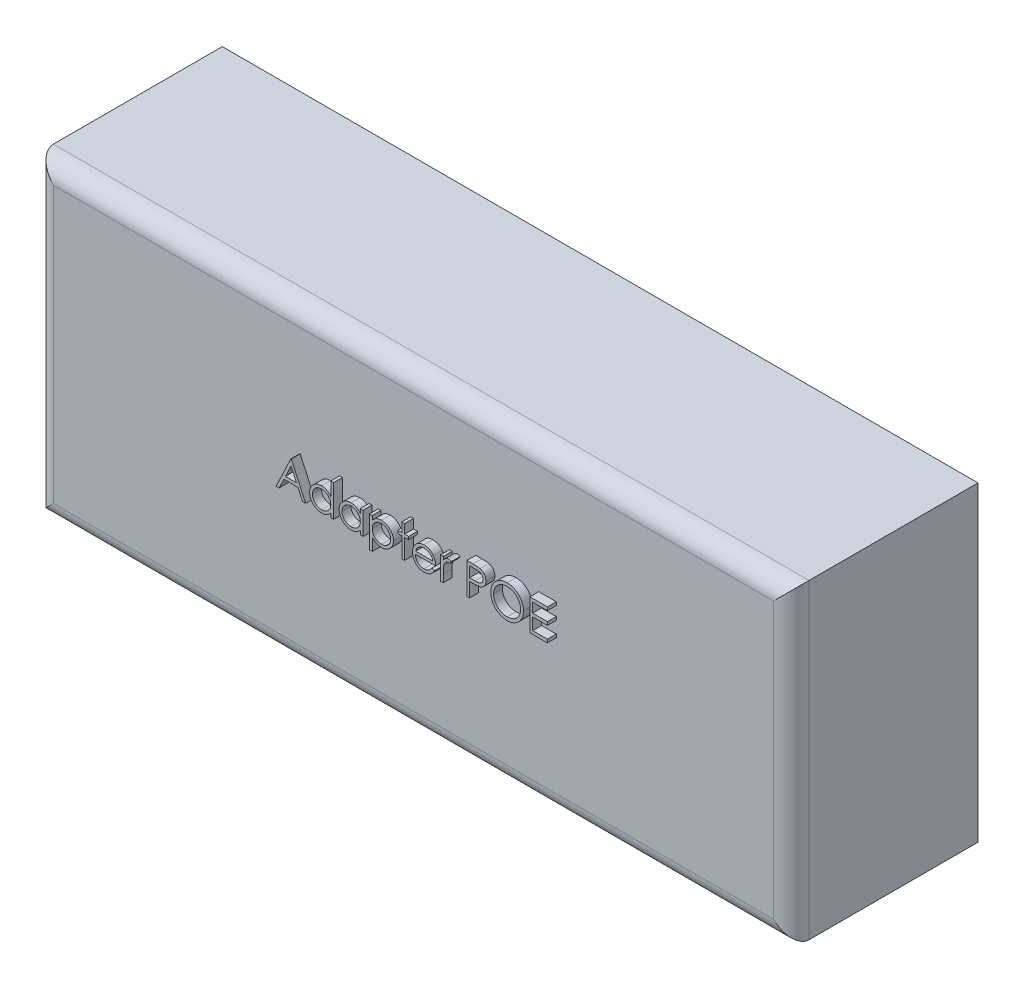
from build123d import *

# Parameters (mm, degrees)
SKETCH1_W           = 85
SKETCH1_H           = 35
BOSS_EXTRUDE1_DEPTH = 21
FILLET1_R           = 2
BOSS_EXTRUDE2_DEPTH = 1


with BuildPart() as part:
    # Sketch1 → Boss-Extrude1 (new body)
    with BuildSketch(Plane.XY):
        Rectangle(SKETCH1_W, SKETCH1_H)
    extrude(amount=BOSS_EXTRUDE1_DEPTH)

    # Fillet1
    fillet1_edges = [part.edges().sort_by_distance(p)[0] for p in [
        (-42.5, 0, 21),
        (0, -17.5, 21),
        (42.5, 0, 21),
        (0, 17.5, 21),
    ]]
    fillet(fillet1_edges, radius=FILLET1_R)

    # Sketch2 → Boss-Extrude2 (add)
    with BuildSketch(Plane.XY.offset(21)):
        Polygon((-12.739406082, 3.203500966), (-11.124021466, -0.296499034), (-11.46546778, -0.296499034), (-11.982895665, 0.825295838), (-13.569534287, 0.825295838), (-14.101685729, -0.296499034), (-14.444534287, -0.296499034), (-12.784277877, 3.203500966), align=None)
        Polygon((-12.765347588, 2.521309459), (-13.399161691, 1.184270197), (-12.148360409, 1.184270197), align=None, mode=Mode.SUBTRACT)
        with BuildLine():
            Line((-7.982995825, 3.293244556), (-7.982995825, -0.296499034))
            Line((-7.982995825, -0.296499034), (-8.297098389, -0.296499034))
            Line((-8.297098389, -0.296499034), (-8.297098389, 0.145908818))
            add(Edge.make_bspline(
                [(-8.297098389, 0.145908818), (-8.33251718, 0.105869225), (-8.401637395, 0.027731453), (-8.517078513, -0.074350719), (-8.639446691, -0.158729041), (-8.768148012, -0.226878956), (-8.903066256, -0.278071013), (-9.043902343, -0.314457172), (-9.190713724, -0.337851007), (-9.290966079, -0.340187029), (-9.341769864, -0.341370829)],
                knots=[0, 0, 0, 0, 0.000160263, 0.000312755, 0.000460949, 0.000605216, 0.000748578, 0.000892786, 0.001041028, 0.001193333, 0.001193333, 0.001193333, 0.001193333], degree=3))
            add(Edge.make_bspline(
                [(-9.341769864, -0.341370829), (-9.386937818, -0.340144457), (-9.476011022, -0.337725996), (-9.6070401, -0.318963693), (-9.733132349, -0.288833071), (-9.854406922, -0.246932182), (-9.970079067, -0.19135136), (-10.081139164, -0.124810112), (-10.187011856, -0.045569282), (-10.286083395, 0.045018747), (-10.377315395, 0.143413734), (-10.457376668, 0.248359281), (-10.524129748, 0.359401585), (-10.579949828, 0.475134738), (-10.622946173, 0.596449658), (-10.652919807, 0.722926826), (-10.671660254, 0.854416699), (-10.674077714, 0.943956223), (-10.675303518, 0.989358338)],
                knots=[0, 0, 0, 0, 0.000135464, 0.00026714, 0.000396211, 0.000523931, 0.000651257, 0.000780517, 0.000911767, 0.001047265, 0.00118272, 0.001313831, 0.001442491, 0.001570752, 0.001698704, 0.001827775, 0.001960146, 0.00209631, 0.00209631, 0.00209631, 0.00209631], degree=3))
            add(Edge.make_bspline(
                [(-10.675303518, 0.989358338), (-10.674050546, 1.033822041), (-10.671573489, 1.121724385), (-10.653120269, 1.251003083), (-10.622089261, 1.375521343), (-10.578541413, 1.494878287), (-10.522699458, 1.609218337), (-10.454771371, 1.718622362), (-10.374752246, 1.823391759), (-10.282499839, 1.921062986), (-10.182565069, 2.0112836), (-10.075656338, 2.089692646), (-9.964433057, 2.157409495), (-9.847170047, 2.211062971), (-9.725602942, 2.254472075), (-9.598649496, 2.284505043), (-9.466837917, 2.302202365), (-9.377347425, 2.304765129), (-9.331954159, 2.306065068)],
                knots=[0, 0, 0, 0, 0.000133363, 0.00026365, 0.000390846, 0.000517716, 0.000644083, 0.000771912, 0.000903449, 0.001038867, 0.001174416, 0.001306792, 0.001436052, 0.00156435, 0.001692963, 0.001822716, 0.001954992, 0.002091156, 0.002091156, 0.002091156, 0.002091156], degree=3))
            add(Edge.make_bspline(
                [(-9.331954159, 2.306065068), (-9.279737351, 2.304497972), (-9.17724156, 2.301421937), (-9.027343039, 2.27571557), (-8.885555428, 2.232552692), (-8.751062441, 2.173461411), (-8.62466588, 2.09666066), (-8.50543924, 2.003909212), (-8.395455917, 1.892582066), (-8.330384094, 1.808970492), (-8.297098389, 1.766201286)],
                knots=[0, 0, 0, 0, 0.000156576, 0.000307342, 0.000454614, 0.000600266, 0.00074684, 0.00089719, 0.001052366, 0.001214863, 0.001214863, 0.001214863, 0.001214863], degree=3))
            Line((-8.297098389, 1.766201286), (-8.297098389, 3.293244556))
            Line((-8.297098389, 3.293244556), (-7.982995825, 3.293244556))
        make_face()
        with BuildLine():
            add(Edge.make_bspline(
                [(-9.327747428, 1.991962504), (-9.373661766, 1.990328867), (-9.464289366, 1.987104326), (-9.597333368, 1.96193083), (-9.724646782, 1.920046236), (-9.845592856, 1.862764335), (-9.958261073, 1.790735598), (-10.058954744, 1.703614215), (-10.148497445, 1.603777201), (-10.223805709, 1.49167509), (-10.285196206, 1.371496999), (-10.328363238, 1.245872561), (-10.356832485, 1.117067584), (-10.359741006, 1.029704898), (-10.361200953, 0.985852729)],
                knots=[0, 0, 0, 0, 0.000137677, 0.000271753, 0.000404561, 0.000538791, 0.000672205, 0.000804452, 0.00093703, 0.001073348, 0.00120849, 0.001340643, 0.001470999, 0.001602378, 0.001602378, 0.001602378, 0.001602378], degree=3))
            add(Edge.make_bspline(
                [(-10.361200953, 0.985852729), (-10.35933606, 0.942262622), (-10.355613583, 0.855253266), (-10.328862889, 0.726272689), (-10.283983015, 0.600618647), (-10.222740953, 0.479357653), (-10.146054328, 0.366773553), (-10.057165675, 0.26503343), (-9.955215394, 0.177543842), (-9.842287887, 0.104306269), (-9.721679917, 0.045143748), (-9.594845985, 0.003978108), (-9.464170347, -0.022599672), (-9.375318013, -0.025704149), (-9.330551915, -0.027268265)],
                knots=[0, 0, 0, 0, 0.000130727, 0.000260941, 0.000393327, 0.000530037, 0.000667328, 0.000800955, 0.000934191, 0.001068956, 0.001203792, 0.001335934, 0.001468075, 0.001602253, 0.001602253, 0.001602253, 0.001602253], degree=3))
            add(Edge.make_bspline(
                [(-9.330551915, -0.027268265), (-9.285105412, -0.025608301), (-9.194716826, -0.022306797), (-9.061278118, 0.002974468), (-8.931783155, 0.044743266), (-8.807995927, 0.102642393), (-8.692679795, 0.174399749), (-8.589181918, 0.25840684), (-8.501665949, 0.356110024), (-8.42747334, 0.463486477), (-8.369297923, 0.581198474), (-8.326921864, 0.706532664), (-8.301867958, 0.839493412), (-8.298710229, 0.930357339), (-8.297098389, 0.976738145)],
                knots=[0, 0, 0, 0, 0.000136278, 0.000271043, 0.000405851, 0.000543552, 0.000679927, 0.000812429, 0.000941985, 0.001072088, 0.00120284, 0.001334538, 0.001467925, 0.001607002, 0.001607002, 0.001607002, 0.001607002], degree=3))
            add(Edge.make_bspline(
                [(-8.297098389, 0.976738145), (-8.298058046, 1.012075976), (-8.299946953, 1.081632009), (-8.314377523, 1.183759527), (-8.337332449, 1.281493253), (-8.369678619, 1.374935942), (-8.412169904, 1.463570957), (-8.463417669, 1.548034718), (-8.524323119, 1.627887929), (-8.593905815, 1.702031), (-8.670071018, 1.769657462), (-8.750665558, 1.830021703), (-8.836644305, 1.879610476), (-8.926561342, 1.920651747), (-9.020572677, 1.953310897), (-9.119443297, 1.975098591), (-9.222122283, 1.990058912), (-9.292168339, 1.991321293), (-9.327747428, 1.991962504)],
                knots=[0, 0, 0, 0, 0.000105983, 0.000208608, 0.000308773, 0.00040678, 0.000504626, 0.000603105, 0.000702667, 0.00080535, 0.000907651, 0.001007914, 0.001106881, 0.00120477, 0.001304102, 0.001404791, 0.00150811, 0.001614764, 0.001614764, 0.001614764, 0.001614764], degree=3))
        make_face(mode=Mode.SUBTRACT)
        with BuildLine():
            Line((-4.662483005, 2.261193274), (-4.662483005, -0.296499034))
            Line((-4.662483005, -0.296499034), (-4.976585569, -0.296499034))
            Line((-4.976585569, -0.296499034), (-4.976585569, 0.145908818))
            add(Edge.make_bspline(
                [(-4.976585569, 0.145908818), (-5.012004359, 0.105869225), (-5.081124575, 0.027731453), (-5.196565693, -0.074350719), (-5.318933871, -0.158729041), (-5.447635192, -0.226878956), (-5.582553435, -0.278071013), (-5.723389522, -0.314457172), (-5.870200903, -0.337851007), (-5.970453258, -0.340187029), (-6.021257043, -0.341370829)],
                knots=[0, 0, 0, 0, 0.000160263, 0.000312755, 0.000460949, 0.000605216, 0.000748578, 0.000892786, 0.001041028, 0.001193333, 0.001193333, 0.001193333, 0.001193333], degree=3))
            add(Edge.make_bspline(
                [(-6.021257043, -0.341370829), (-6.066424997, -0.340144457), (-6.155498202, -0.337725996), (-6.286527279, -0.318963693), (-6.412619528, -0.288833071), (-6.533894101, -0.246932182), (-6.649566247, -0.19135136), (-6.760626343, -0.124810112), (-6.866499035, -0.045569282), (-6.965570574, 0.045018747), (-7.056802575, 0.143413734), (-7.136863847, 0.248359281), (-7.203616927, 0.359401585), (-7.259437008, 0.475134738), (-7.302433352, 0.596449658), (-7.332406986, 0.722926826), (-7.351147433, 0.854416699), (-7.353564894, 0.943956223), (-7.354790697, 0.989358338)],
                knots=[0, 0, 0, 0, 0.000135464, 0.00026714, 0.000396211, 0.000523931, 0.000651257, 0.000780517, 0.000911767, 0.001047265, 0.00118272, 0.001313831, 0.001442491, 0.001570752, 0.001698704, 0.001827775, 0.001960146, 0.00209631, 0.00209631, 0.00209631, 0.00209631], degree=3))
            add(Edge.make_bspline(
                [(-7.354790697, 0.989358338), (-7.353537726, 1.033822041), (-7.351060669, 1.121724385), (-7.332607449, 1.251003083), (-7.30157644, 1.375521343), (-7.258028593, 1.494878287), (-7.202186638, 1.609218337), (-7.134258551, 1.718622362), (-7.054239426, 1.823391759), (-6.961987019, 1.921062986), (-6.862052249, 2.0112836), (-6.755143518, 2.089692646), (-6.643920237, 2.157409495), (-6.526657226, 2.211062971), (-6.405090121, 2.254472075), (-6.278136675, 2.284505043), (-6.146325097, 2.302202365), (-6.056834605, 2.304765129), (-6.011441338, 2.306065068)],
                knots=[0, 0, 0, 0, 0.000133363, 0.00026365, 0.000390846, 0.000517716, 0.000644083, 0.000771912, 0.000903449, 0.001038867, 0.001174416, 0.001306792, 0.001436052, 0.00156435, 0.001692963, 0.001822716, 0.001954992, 0.002091156, 0.002091156, 0.002091156, 0.002091156], degree=3))
            add(Edge.make_bspline(
                [(-6.011441338, 2.306065068), (-5.959241479, 2.304627317), (-5.856880019, 2.301807954), (-5.70715201, 2.278345227), (-5.565507532, 2.23870676), (-5.43085318, 2.184789262), (-5.303672494, 2.113140532), (-5.185169509, 2.022760571), (-5.074104026, 1.914219384), (-5.009723734, 1.83084894), (-4.976585569, 1.787936062)],
                knots=[0, 0, 0, 0, 0.00015654, 0.000306968, 0.000453261, 0.000596998, 0.000741098, 0.000889738, 0.001042937, 0.001205434, 0.001205434, 0.001205434, 0.001205434], degree=3))
            Line((-4.976585569, 1.787936062), (-4.976585569, 2.261193274))
            Line((-4.976585569, 2.261193274), (-4.662483005, 2.261193274))
        make_face()
        with BuildLine():
            add(Edge.make_bspline(
                [(-6.007234607, 1.991962504), (-6.053148945, 1.990328867), (-6.143776545, 1.987104326), (-6.276820547, 1.96193083), (-6.404133961, 1.920046236), (-6.525080036, 1.862764335), (-6.637748252, 1.790735598), (-6.738441923, 1.703614215), (-6.827984624, 1.603777201), (-6.903292889, 1.49167509), (-6.964683386, 1.371496999), (-7.007850417, 1.245872561), (-7.036319665, 1.117067584), (-7.039228185, 1.029704898), (-7.040688133, 0.985852729)],
                knots=[0, 0, 0, 0, 0.000137677, 0.000271753, 0.000404561, 0.000538791, 0.000672205, 0.000804452, 0.00093703, 0.001073348, 0.00120849, 0.001340643, 0.001470999, 0.001602378, 0.001602378, 0.001602378, 0.001602378], degree=3))
            add(Edge.make_bspline(
                [(-7.040688133, 0.985852729), (-7.03882324, 0.942262622), (-7.035100763, 0.855253266), (-7.008350068, 0.726272689), (-6.963470195, 0.600618647), (-6.902228132, 0.479357653), (-6.825541507, 0.366773553), (-6.736652855, 0.26503343), (-6.634702574, 0.177543842), (-6.521775067, 0.104306269), (-6.401167096, 0.045143748), (-6.274333165, 0.003978108), (-6.143657526, -0.022599672), (-6.054805193, -0.025704149), (-6.010039094, -0.027268265)],
                knots=[0, 0, 0, 0, 0.000130727, 0.000260941, 0.000393327, 0.000530037, 0.000667328, 0.000800955, 0.000934191, 0.001068956, 0.001203792, 0.001335934, 0.001468075, 0.001602253, 0.001602253, 0.001602253, 0.001602253], degree=3))
            add(Edge.make_bspline(
                [(-6.010039094, -0.027268265), (-5.964592592, -0.025608301), (-5.874204005, -0.022306797), (-5.740765297, 0.002974468), (-5.611270334, 0.044743266), (-5.487483106, 0.102642393), (-5.372166975, 0.174399749), (-5.268669097, 0.25840684), (-5.181153129, 0.356110024), (-5.106960519, 0.463486477), (-5.048785103, 0.581198474), (-5.006409044, 0.706532664), (-4.981355138, 0.839493412), (-4.978197408, 0.930357339), (-4.976585569, 0.976738145)],
                knots=[0, 0, 0, 0, 0.000136278, 0.000271043, 0.000405851, 0.000543552, 0.000679927, 0.000812429, 0.000941985, 0.001072088, 0.00120284, 0.001334538, 0.001467925, 0.001607002, 0.001607002, 0.001607002, 0.001607002], degree=3))
            add(Edge.make_bspline(
                [(-4.976585569, 0.976738145), (-4.977545225, 1.012075976), (-4.979434133, 1.081632009), (-4.993864702, 1.183759527), (-5.016819629, 1.281493253), (-5.049165799, 1.374935942), (-5.091657083, 1.463570957), (-5.142904849, 1.548034718), (-5.203810299, 1.627887929), (-5.273392995, 1.702031), (-5.349558197, 1.769657462), (-5.430152738, 1.830021703), (-5.516131485, 1.879610476), (-5.606048522, 1.920651747), (-5.700059856, 1.953310897), (-5.798930476, 1.975098591), (-5.901609463, 1.990058912), (-5.971655518, 1.991321293), (-6.007234607, 1.991962504)],
                knots=[0, 0, 0, 0, 0.000105983, 0.000208608, 0.000308773, 0.00040678, 0.000504626, 0.000603105, 0.000702667, 0.00080535, 0.000907651, 0.001007914, 0.001106881, 0.00120477, 0.001304102, 0.001404791, 0.00150811, 0.001614764, 0.001614764, 0.001614764, 0.001614764], degree=3))
        make_face(mode=Mode.SUBTRACT)
        with BuildLine():
            Line((-3.944534287, 2.261193274), (-3.630431723, 2.261193274))
            Line((-3.630431723, 2.261193274), (-3.630431723, 1.787936062))
            add(Edge.make_bspline(
                [(-3.630431723, 1.787936062), (-3.597074239, 1.830873796), (-3.532250644, 1.914314689), (-3.420525739, 2.022304817), (-3.30259893, 2.113380121), (-3.175435518, 2.184762654), (-3.041011828, 2.238583466), (-2.89987951, 2.278362916), (-2.750840745, 2.30180439), (-2.648944293, 2.304626052), (-2.596978197, 2.306065068)],
                knots=[0, 0, 0, 0, 0.00016294, 0.00031664, 0.000464722, 0.000608822, 0.000752559, 0.000898176, 0.001047911, 0.001203751, 0.001203751, 0.001203751, 0.001203751], degree=3))
            add(Edge.make_bspline(
                [(-2.596978197, 2.306065068), (-2.551586594, 2.30475189), (-2.461867706, 2.302156323), (-2.329804477, 2.284583268), (-2.202629093, 2.254465576), (-2.081061039, 2.21106466), (-1.963797974, 2.15740919), (-1.852575874, 2.089692155), (-1.745662318, 2.011285964), (-1.645746129, 1.921053813), (-1.553424762, 1.823425547), (-1.473578581, 1.718403242), (-1.404706676, 1.609440656), (-1.34903638, 1.494848564), (-1.305428033, 1.375529334), (-1.274413355, 1.251000893), (-1.255955711, 1.121724953), (-1.25347926, 1.033822232), (-1.252226594, 0.989358338)],
                knots=[0, 0, 0, 0, 0.000136164, 0.000269135, 0.000398888, 0.000527501, 0.000655799, 0.000785059, 0.000917435, 0.001052984, 0.001188402, 0.001319939, 0.001448139, 0.001574506, 0.001701376, 0.001828571, 0.001958859, 0.002092222, 0.002092222, 0.002092222, 0.002092222], degree=3))
            add(Edge.make_bspline(
                [(-1.252226594, 0.989358338), (-1.25345208, 0.943956029), (-1.255868914, 0.854416125), (-1.27461392, 0.722929027), (-1.304570794, 0.596441654), (-1.347628978, 0.47516439), (-1.403270466, 0.359180739), (-1.470975026, 0.248574343), (-1.550861493, 0.14338064), (-1.642162621, 0.045027739), (-1.741215557, -0.045571573), (-1.847093047, -0.124809643), (-1.958151972, -0.191351018), (-2.073824139, -0.246933978), (-2.195099778, -0.288826162), (-2.321413056, -0.319043963), (-2.452695202, -0.337678458), (-2.541996354, -0.340130601), (-2.587162492, -0.341370829)],
                knots=[0, 0, 0, 0, 0.000136164, 0.000268535, 0.000397606, 0.000525558, 0.00065382, 0.000782843, 0.000913955, 0.001049409, 0.001184907, 0.001316158, 0.001445417, 0.001572744, 0.001700463, 0.001829535, 0.001961906, 0.002097369, 0.002097369, 0.002097369, 0.002097369], degree=3))
            add(Edge.make_bspline(
                [(-2.587162492, -0.341370829), (-2.637990064, -0.340076021), (-2.73838942, -0.337518396), (-2.88518709, -0.311598986), (-3.026463942, -0.272862051), (-3.160654767, -0.216163057), (-3.288822579, -0.143907541), (-3.410242385, -0.055797335), (-3.525559138, 0.04798329), (-3.594967895, 0.126715106), (-3.630431723, 0.166942472)],
                knots=[0, 0, 0, 0, 0.000152339, 0.000300914, 0.000445856, 0.000591043, 0.000736709, 0.000886352, 0.001040245, 0.001201023, 0.001201023, 0.001201023, 0.001201023], degree=3))
            Line((-3.630431723, 0.166942472), (-3.630431723, -1.238806726))
            Line((-3.630431723, -1.238806726), (-3.944534287, -1.238806726))
            Line((-3.944534287, -1.238806726), (-3.944534287, 2.261193274))
        make_face()
        with BuildLine():
            add(Edge.make_bspline(
                [(-2.599782684, 1.991962504), (-2.635362247, 1.991322246), (-2.705409234, 1.990061743), (-2.808081453, 1.975087794), (-2.906976881, 1.953350053), (-3.001098833, 1.920438153), (-3.091349449, 1.880039339), (-3.177033614, 1.829557328), (-3.258091181, 1.769905322), (-3.334318212, 1.702225978), (-3.403181505, 1.62765129), (-3.464144433, 1.548063481), (-3.515351738, 1.463563342), (-3.557853759, 1.374937979), (-3.590197041, 1.281492694), (-3.613152761, 1.183759681), (-3.627583114, 1.081631969), (-3.629472051, 1.012075962), (-3.630431723, 0.976738145)],
                knots=[0, 0, 0, 0, 0.000106654, 0.000209973, 0.000310662, 0.000409994, 0.000508521, 0.000606883, 0.00070771, 0.000810012, 0.000912217, 0.001011779, 0.001110258, 0.001208104, 0.001306111, 0.001406276, 0.001508901, 0.001614884, 0.001614884, 0.001614884, 0.001614884], degree=3))
            add(Edge.make_bspline(
                [(-3.630431723, 0.976738145), (-3.628840867, 0.930350033), (-3.625724245, 0.839471792), (-3.600386877, 0.70668767), (-3.559151613, 0.581036014), (-3.500622899, 0.463574977), (-3.426675325, 0.355592142), (-3.337577168, 0.258901536), (-3.234134617, 0.174110945), (-3.118067426, 0.102689691), (-2.993645295, 0.044701625), (-2.863859383, 0.003187414), (-2.730494502, -0.022384814), (-2.640326182, -0.025631633), (-2.594874832, -0.027268265)],
                knots=[0, 0, 0, 0, 0.000139077, 0.000272463, 0.00040394, 0.000534691, 0.000664794, 0.000795295, 0.000927798, 0.001064768, 0.001203104, 0.001338581, 0.001472656, 0.001608934, 0.001608934, 0.001608934, 0.001608934], degree=3))
            add(Edge.make_bspline(
                [(-2.594874832, -0.027268265), (-2.550339064, -0.025711888), (-2.461943571, -0.02262276), (-2.331785449, 0.004115428), (-2.205294811, 0.044960452), (-2.085114638, 0.104520009), (-1.972291151, 0.177510067), (-1.870409597, 0.2650701), (-1.781402683, 0.366560043), (-1.705538328, 0.479568546), (-1.644406843, 0.60074393), (-1.598476603, 0.726125318), (-1.57196803, 0.855270742), (-1.568211241, 0.942268454), (-1.566329159, 0.985852729)],
                knots=[0, 0, 0, 0, 0.000133479, 0.000264931, 0.000397073, 0.000531279, 0.000666044, 0.000799279, 0.000932907, 0.001069805, 0.001206515, 0.001339137, 0.001469351, 0.001600078, 0.001600078, 0.001600078, 0.001600078], degree=3))
            add(Edge.make_bspline(
                [(-1.566329159, 0.985852729), (-1.567783892, 1.029707718), (-1.570682026, 1.117076022), (-1.599229064, 1.245838925), (-1.642129042, 1.371726901), (-1.704688094, 1.49124745), (-1.778889363, 1.604021533), (-1.86863636, 1.703575412), (-1.969252556, 1.790746085), (-2.08194172, 1.862761495), (-2.202882146, 1.92004699), (-2.330197062, 1.961930628), (-2.463240664, 1.987104378), (-2.553868319, 1.990328884), (-2.599782684, 1.991962504)],
                knots=[0, 0, 0, 0, 0.000131379, 0.000261735, 0.000393889, 0.000529349, 0.000665274, 0.000797853, 0.0009301, 0.001063514, 0.001197743, 0.001330552, 0.001464627, 0.001602305, 0.001602305, 0.001602305, 0.001602305], degree=3))
        make_face(mode=Mode.SUBTRACT)
        Polygon((-0.309918902, 3.293244556), (0.004183662, 3.293244556), (0.004183662, 2.261193274), (0.452901611, 2.261193274), (0.452901611, 1.947090709), (0.004183662, 1.947090709), (0.004183662, -0.296499034), (-0.309918902, -0.296499034), (-0.309918902, 1.947090709), (-0.758636851, 1.947090709), (-0.758636851, 2.261193274), (-0.309918902, 2.261193274), align=None)
        with BuildLine():
            Line((3.090521803, 0.511193274), (3.369568277, 0.364658818))
            add(Edge.make_bspline(
                [(3.369568277, 0.364658818), (3.347331682, 0.325215487), (3.304068074, 0.248474384), (3.229667326, 0.143042524), (3.151675253, 0.048194808), (3.066571285, -0.033534846), (2.976901606, -0.104786231), (2.882168951, -0.167124056), (2.781880134, -0.220242576), (2.676030409, -0.264995104), (2.563730858, -0.299404598), (2.444709341, -0.323708819), (2.318737846, -0.338732088), (2.232391666, -0.340477229), (2.188178053, -0.341370829)],
                knots=[0, 0, 0, 0, 0.000135759, 0.000264133, 0.000386579, 0.000503597, 0.000617365, 0.000729763, 0.000843304, 0.000957371, 0.001074023, 0.001195027, 0.001321389, 0.001453992, 0.001453992, 0.001453992, 0.001453992], degree=3))
            add(Edge.make_bspline(
                [(2.188178053, -0.341370829), (2.139036075, -0.340223654), (2.043174314, -0.337985847), (1.903634567, -0.318693382), (1.772255148, -0.287221024), (1.649043445, -0.243255482), (1.534301192, -0.185828158), (1.427800338, -0.115868676), (1.328980812, -0.033736422), (1.240956602, 0.061280022), (1.16171272, 0.162961979), (1.0917869, 0.268917864), (1.033329469, 0.378881088), (0.985776859, 0.492151612), (0.947371994, 0.608015506), (0.92060529, 0.727526973), (0.905175542, 0.850362557), (0.902811096, 0.933459893), (0.901619559, 0.975335902)],
                knots=[0, 0, 0, 0, 0.000147371, 0.000287478, 0.000421649, 0.000552053, 0.000679042, 0.000805636, 0.000933558, 0.00106351, 0.001193382, 0.001319977, 0.001443869, 0.001566405, 0.001688128, 0.001809576, 0.001933238, 0.002058864, 0.002058864, 0.002058864, 0.002058864], degree=3))
            add(Edge.make_bspline(
                [(0.901619559, 0.975335902), (0.902678701, 1.014630732), (0.904777779, 1.092507897), (0.918008566, 1.207773441), (0.941456859, 1.319801894), (0.973633183, 1.428686342), (1.01518443, 1.534244476), (1.066016649, 1.63654054), (1.126209027, 1.735465679), (1.1726817, 1.797868813), (1.196090713, 1.829302248)],
                knots=[0, 0, 0, 0, 0.000117891, 0.000233644, 0.000347498, 0.000460856, 0.000573868, 0.000687374, 0.000803169, 0.000920699, 0.000920699, 0.000920699, 0.000920699], degree=3))
            add(Edge.make_bspline(
                [(1.196090713, 1.829302248), (1.227798396, 1.867171118), (1.290209343, 1.941709268), (1.395765698, 2.039647594), (1.510065894, 2.121691369), (1.63167752, 2.189698506), (1.762013994, 2.241372153), (1.899323286, 2.279879735), (2.045168872, 2.301457746), (2.144874093, 2.304505579), (2.195890393, 2.306065068)],
                knots=[0, 0, 0, 0, 0.000148071, 0.000291452, 0.00043058, 0.000569298, 0.000708346, 0.00085021, 0.000996268, 0.001149307, 0.001149307, 0.001149307, 0.001149307], degree=3))
            add(Edge.make_bspline(
                [(2.195890393, 2.306065068), (2.248337998, 2.30471102), (2.351228244, 2.302054684), (2.501260365, 2.277428351), (2.643221082, 2.238375796), (2.777053586, 2.183222006), (2.902771447, 2.112062454), (3.019557496, 2.023920613), (3.129409009, 1.921502525), (3.193317588, 1.842739316), (3.225838309, 1.80265962)],
                knots=[0, 0, 0, 0, 0.000157241, 0.00030847, 0.000454763, 0.000598116, 0.000741606, 0.000886879, 0.001036172, 0.001190853, 0.001190853, 0.001190853, 0.001190853], degree=3))
            add(Edge.make_bspline(
                [(3.225838309, 1.80265962), (3.247965248, 1.772456038), (3.292071841, 1.71224992), (3.347318941, 1.614078763), (3.395276336, 1.511368168), (3.433609297, 1.402457871), (3.464648798, 1.288638291), (3.487105617, 1.169095746), (3.500275235, 1.043865835), (3.502863933, 0.958539279), (3.504183662, 0.915039427)],
                knots=[0, 0, 0, 0, 0.000112234, 0.000223721, 0.000337279, 0.000451932, 0.000569628, 0.000690912, 0.000816421, 0.00094695, 0.00094695, 0.00094695, 0.00094695], degree=3))
            Line((3.504183662, 0.915039427), (1.215722123, 0.915039427))
            add(Edge.make_bspline(
                [(1.215722123, 0.915039427), (1.21726173, 0.881338963), (1.220289304, 0.815068359), (1.234404447, 0.718097576), (1.256653221, 0.625724234), (1.287922283, 0.538641192), (1.325789129, 0.455711065), (1.372174845, 0.377549028), (1.427514399, 0.304511098), (1.489240099, 0.23594396), (1.557947194, 0.174883199), (1.630229941, 0.120231423), (1.707123506, 0.074425826), (1.78802159, 0.037245936), (1.872793375, 0.00813962), (1.96146557, -0.011728201), (2.053863686, -0.025035307), (2.116849421, -0.026514973), (2.148915232, -0.027268265)],
                knots=[0, 0, 0, 0, 0.000101159, 0.000198924, 0.000293472, 0.000385722, 0.000476069, 0.000566611, 0.000657757, 0.000750573, 0.000842919, 0.000933083, 0.001022062, 0.001110842, 0.001199752, 0.001290403, 0.001383113, 0.001479259, 0.001479259, 0.001479259, 0.001479259], degree=3))
            add(Edge.make_bspline(
                [(2.148915232, -0.027268265), (2.18026638, -0.026660208), (2.242473071, -0.025453707), (2.335113928, -0.013721796), (2.426253456, 0.005248479), (2.515514439, 0.031138469), (2.601085285, 0.062715322), (2.680330835, 0.100818179), (2.753211051, 0.142967926), (2.821328017, 0.191177601), (2.887399011, 0.250185788), (2.952941497, 0.323821509), (3.02321815, 0.410909037), (3.067207743, 0.476454703), (3.090521803, 0.511193274)],
                knots=[0, 0, 0, 0, 9.4016e-05, 0.000186545, 0.000279636, 0.000373054, 0.000465125, 0.000552934, 0.000636508, 0.000717442, 0.000802858, 0.000901616, 0.001012865, 0.001138311, 0.001138311, 0.001138311, 0.001138311], degree=3))
        make_face()
        with BuildLine():
            add(Edge.make_bspline(
                [(3.190081098, 1.229141992), (3.178584473, 1.270804865), (3.156457172, 1.350992486), (3.110220807, 1.462033376), (3.058149267, 1.560721277), (2.996527535, 1.64630091), (2.92670881, 1.722304423), (2.846063627, 1.788723009), (2.755627734, 1.84814046), (2.655868593, 1.898292959), (2.550226808, 1.940982818), (2.439620616, 1.969607934), (2.326762828, 1.989217476), (2.250428542, 1.991043584), (2.212016194, 1.991962504)],
                knots=[0, 0, 0, 0, 0.000129543, 0.000249328, 0.000360065, 0.000463575, 0.000564789, 0.000668832, 0.000776175, 0.000888744, 0.001003316, 0.001117263, 0.001230914, 0.001346035, 0.001346035, 0.001346035, 0.001346035], degree=3))
            add(Edge.make_bspline(
                [(2.212016194, 1.991962504), (2.180666755, 1.991350833), (2.118695506, 1.990141687), (2.027394438, 1.978671557), (1.939714739, 1.959711713), (1.855009452, 1.933746756), (1.774388583, 1.899138153), (1.696193815, 1.858554927), (1.622413419, 1.809013343), (1.576272123, 1.771254488), (1.552961707, 1.752178851)],
                knots=[0, 0, 0, 0, 9.4016e-05, 0.000185849, 0.000275511, 0.000362884, 0.000451173, 0.00053836, 0.000626838, 0.000717174, 0.000717174, 0.000717174, 0.000717174], degree=3))
            add(Edge.make_bspline(
                [(1.552961707, 1.752178851), (1.536268425, 1.737084535), (1.502485291, 1.706537319), (1.457344769, 1.653908112), (1.414124296, 1.59715655), (1.374790644, 1.534111426), (1.338713057, 1.465490647), (1.30495308, 1.391873011), (1.274566668, 1.312699881), (1.257470558, 1.257527442), (1.248674848, 1.229141992)],
                knots=[0, 0, 0, 0, 6.7454e-05, 0.00013651, 0.000207604, 0.000281328, 0.000359112, 0.000440057, 0.000524171, 0.000613305, 0.000613305, 0.000613305, 0.000613305], degree=3))
            Line((1.248674848, 1.229141992), (3.190081098, 1.229141992))
        make_face(mode=Mode.SUBTRACT)
        with BuildLine():
            Line((4.0426452, 2.261193274), (4.356747765, 2.261193274))
            Line((4.356747765, 2.261193274), (4.356747765, 1.88469087))
            add(Edge.make_bspline(
                [(4.356747765, 1.88469087), (4.379936523, 1.919746698), (4.424284844, 1.986790697), (4.497997774, 2.075459998), (4.573501105, 2.148875045), (4.651156292, 2.207378564), (4.731534392, 2.251191683), (4.812871344, 2.283284718), (4.896446814, 2.302262033), (4.952608738, 2.304795692), (4.980746162, 2.306065068)],
                knots=[0, 0, 0, 0, 0.000126023, 0.000241017, 0.000345147, 0.000441342, 0.00053171, 0.000618946, 0.000702978, 0.000787349, 0.000787349, 0.000787349, 0.000787349], degree=3))
            add(Edge.make_bspline(
                [(4.980746162, 2.306065068), (5.002572488, 2.304874542), (5.047481574, 2.302424956), (5.115464163, 2.285214131), (5.185507615, 2.257736109), (5.230650003, 2.231895886), (5.254183662, 2.218424844)],
                knots=[0, 0, 0, 0, 6.5445e-05, 0.000134658, 0.00020926, 0.000290509, 0.000290509, 0.000290509, 0.000290509], degree=3))
            Line((5.254183662, 2.218424844), (5.0817077, 1.946389588))
            add(Edge.make_bspline(
                [(5.0817077, 1.946389588), (5.066598679, 1.953129854), (5.037918865, 1.965924169), (4.995964298, 1.981066179), (4.957282962, 1.989982095), (4.932639403, 1.991332813), (4.921150809, 1.991962504)],
                knots=[0, 0, 0, 0, 4.9621e-05, 9.4191e-05, 0.00013366, 0.000168129, 0.000168129, 0.000168129, 0.000168129], degree=3))
            add(Edge.make_bspline(
                [(4.921150809, 1.991962504), (4.895945076, 1.990282467), (4.844532686, 1.986855678), (4.769048187, 1.95991687), (4.695800981, 1.91639163), (4.637629319, 1.868120518), (4.592587066, 1.821572721), (4.56044684, 1.780924318), (4.530964093, 1.735345686), (4.502793873, 1.685616003), (4.477127579, 1.630886157), (4.453172909, 1.571702943), (4.431514047, 1.507997814), (4.419163802, 1.463615294), (4.412837508, 1.440880774)],
                knots=[0, 0, 0, 0, 7.549e-05, 0.000153978, 0.000237553, 0.000330197, 0.000379784, 0.000431685, 0.000485357, 0.000542493, 0.000603021, 0.000666557, 0.00073396, 0.000804745, 0.000804745, 0.000804745, 0.000804745], degree=3))
            add(Edge.make_bspline(
                [(4.412837508, 1.440880774), (4.408105115, 1.4206036), (4.397623223, 1.375691201), (4.387431685, 1.300342677), (4.377362167, 1.211319018), (4.370265549, 1.108372425), (4.363687507, 0.991759981), (4.359977425, 0.861304035), (4.356874284, 0.716870684), (4.356791217, 0.615896331), (4.356747765, 0.563076286)],
                knots=[0, 0, 0, 0, 6.2435e-05, 0.000138289, 0.000227871, 0.000331224, 0.000447781, 0.000578258, 0.000722716, 0.000881171, 0.000881171, 0.000881171, 0.000881171], degree=3))
            Line((4.356747765, 0.563076286), (4.356747765, -0.296499034))
            Line((4.356747765, -0.296499034), (4.0426452, -0.296499034))
            Line((4.0426452, -0.296499034), (4.0426452, 2.261193274))
        make_face()
        with BuildLine():
            Line((7.004183662, 3.203500966), (7.690581899, 3.203500966))
            add(Edge.make_bspline(
                [(7.690581899, 3.203500966), (7.737792805, 3.20344907), (7.828250998, 3.203349634), (7.957966054, 3.200334888), (8.075775785, 3.196308196), (8.181426166, 3.190726303), (8.275242264, 3.184129713), (8.356799564, 3.174877673), (8.42673912, 3.165217378), (8.46864557, 3.155395971), (8.48775738, 3.150916831)],
                knots=[0, 0, 0, 0, 0.000141628, 0.000271366, 0.00038923, 0.000495248, 0.00058876, 0.000671296, 0.000741499, 0.00080036, 0.00080036, 0.00080036, 0.00080036], degree=3))
            add(Edge.make_bspline(
                [(8.48775738, 3.150916831), (8.511950914, 3.144294881), (8.559767891, 3.13120702), (8.628668934, 3.104993296), (8.694222779, 3.073911131), (8.756654338, 3.038487191), (8.815196421, 2.997201627), (8.870722462, 2.951728009), (8.922742442, 2.901016441), (8.970963834, 2.845635701), (9.015248632, 2.786515491), (9.053378314, 2.722773261), (9.085305541, 2.655481958), (9.112688813, 2.584688387), (9.132397267, 2.509798063), (9.147244167, 2.431331351), (9.156667795, 2.34929666), (9.157570357, 2.293236793), (9.158029816, 2.264698883)],
                knots=[0, 0, 0, 0, 7.5216e-05, 0.00014866, 0.000220794, 0.000292713, 0.000363707, 0.000435434, 0.000507823, 0.000581364, 0.000655543, 0.000729131, 0.000803767, 0.000878771, 0.000956497, 0.001035702, 0.001118238, 0.001203821, 0.001203821, 0.001203821, 0.001203821], degree=3))
            add(Edge.make_bspline(
                [(9.158029816, 2.264698883), (9.157608391, 2.235921106), (9.156783845, 2.179615442), (9.14688756, 2.097242654), (9.133557368, 2.018524264), (9.113060316, 1.943634813), (9.086214643, 1.873019043), (9.05472259, 1.805597811), (9.01673906, 1.742518139), (8.97309423, 1.683551021), (8.924542635, 1.628641109), (8.871289697, 1.578186314), (8.813550405, 1.532481976), (8.751508257, 1.491425632), (8.684558408, 1.455969353), (8.613716254, 1.424212048), (8.538366038, 1.397540987), (8.486223524, 1.383510926), (8.459712508, 1.376377568)],
                knots=[0, 0, 0, 0, 8.6284e-05, 0.00016882, 0.000248587, 0.000325638, 0.000401297, 0.000474998, 0.000548586, 0.000621785, 0.0006948, 0.0007682, 0.000841564, 0.000915458, 0.000991056, 0.00106858, 0.00114819, 0.001230532, 0.001230532, 0.001230532, 0.001230532], degree=3))
            add(Edge.make_bspline(
                [(8.459712508, 1.376377568), (8.437785174, 1.371714587), (8.389730147, 1.361495393), (8.310587425, 1.350086936), (8.218442039, 1.340349336), (8.113419759, 1.333048198), (7.995614854, 1.32679783), (7.864963596, 1.321829736), (7.721209519, 1.319099882), (7.620938275, 1.318959089), (7.568586707, 1.318885581)],
                knots=[0, 0, 0, 0, 6.7238e-05, 0.000147357, 0.000239727, 0.000345177, 0.000463135, 0.000593636, 0.000737393, 0.000894446, 0.000894446, 0.000894446, 0.000894446], degree=3))
            Line((7.568586707, 1.318885581), (7.318286226, 1.318885581))
            Line((7.318286226, 1.318885581), (7.318286226, -0.296499034))
            Line((7.318286226, -0.296499034), (7.004183662, -0.296499034))
            Line((7.004183662, -0.296499034), (7.004183662, 3.203500966))
        make_face()
        with BuildLine():
            Line((7.318286226, 2.844526607), (7.318286226, 1.67785994))
            Line((7.318286226, 1.67785994), (7.931066675, 1.670147601))
            add(Edge.make_bspline(
                [(7.931066675, 1.670147601), (7.960986601, 1.670132137), (8.018746401, 1.670102285), (8.102182624, 1.674087508), (8.179591911, 1.678688041), (8.250736486, 1.685423964), (8.315648421, 1.694945222), (8.37443595, 1.70455696), (8.426643233, 1.718462322), (8.487742434, 1.737185392), (8.555825782, 1.769118007), (8.62989333, 1.815467897), (8.692663917, 1.874548605), (8.746982214, 1.940976437), (8.790088091, 2.014875566), (8.821644084, 2.093944503), (8.840185241, 2.177372352), (8.842671435, 2.234460491), (8.843927252, 2.263296639)],
                knots=[0, 0, 0, 0, 8.9746e-05, 0.000173253, 0.000250533, 0.00032239, 0.000387534, 0.00044736, 0.000500926, 0.000549486, 0.000638903, 0.000725641, 0.000810488, 0.000896226, 0.000982324, 0.00106604, 0.001150757, 0.001237226, 0.001237226, 0.001237226, 0.001237226], degree=3))
            add(Edge.make_bspline(
                [(8.843927252, 2.263296639), (8.842664605, 2.291435152), (8.84015462, 2.347371035), (8.821498757, 2.429349795), (8.790149443, 2.5075855), (8.746692849, 2.580558585), (8.693951719, 2.646747389), (8.632652376, 2.704244516), (8.562939114, 2.750466219), (8.498090883, 2.7802995), (8.440489697, 2.798514776), (8.390457737, 2.811259616), (8.333967063, 2.821435222), (8.270999283, 2.829674725), (8.202042449, 2.836728187), (8.126504135, 2.841514164), (8.044670491, 2.84431562), (7.98785992, 2.844454575), (7.958410425, 2.844526607)],
                knots=[0, 0, 0, 0, 8.4371e-05, 0.000167719, 0.000250783, 0.000336277, 0.000421575, 0.000503926, 0.000587348, 0.000671427, 0.000717102, 0.000768457, 0.000826213, 0.000889178, 0.000958942, 0.001034123, 0.001116202, 0.001204546, 0.001204546, 0.001204546, 0.001204546], degree=3))
            Line((7.958410425, 2.844526607), (7.318286226, 2.844526607))
        make_face(mode=Mode.SUBTRACT)
        with BuildLine():
            add(Edge.make_bspline(
                [(11.513799047, 3.293244556), (11.578607152, 3.291603076), (11.705895619, 3.288379075), (11.892970517, 3.263699972), (12.071565612, 3.221004582), (12.243135751, 3.164141599), (12.405628728, 3.088287214), (12.56026762, 2.996602066), (12.706684494, 2.888125607), (12.842905876, 2.76369638), (12.967562826, 2.628312926), (13.077388712, 2.483835016), (13.169431006, 2.331136214), (13.245016793, 2.170675383), (13.304315403, 2.002815415), (13.345234446, 1.826661412), (13.371372597, 1.643354722), (13.374428374, 1.518327858), (13.375978534, 1.454903209)],
                knots=[0, 0, 0, 0, 0.000194393, 0.000381804, 0.00056479, 0.000744601, 0.000923091, 0.001101652, 0.001283106, 0.001468738, 0.001654324, 0.001834514, 0.002012231, 0.002188181, 0.002365797, 0.002545211, 0.002729936, 0.002920126, 0.002920126, 0.002920126, 0.002920126], degree=3))
            add(Edge.make_bspline(
                [(13.375978534, 1.454903209), (13.374428601, 1.391945763), (13.371373505, 1.267849343), (13.345204727, 1.085705899), (13.304163727, 0.910615202), (13.245567461, 0.742869549), (13.170341983, 0.582291986), (13.077686811, 0.429305032), (12.968545601, 0.283858533), (12.84433875, 0.147545868), (12.708937708, 0.022548397), (12.563707441, -0.086370478), (12.411914121, -0.180094603), (12.251604413, -0.254878277), (12.084904376, -0.314650197), (11.910322053, -0.355402827), (11.728675499, -0.381689871), (11.604804495, -0.384708387), (11.541843918, -0.386242624)],
                knots=[0, 0, 0, 0, 0.000188789, 0.000372126, 0.000550857, 0.00072758, 0.000904164, 0.001081881, 0.001263191, 0.001448823, 0.00163441, 0.001815159, 0.001992641, 0.002168591, 0.002344885, 0.002522934, 0.002705576, 0.002894365, 0.002894365, 0.002894365, 0.002894365], degree=3))
            add(Edge.make_bspline(
                [(11.541843918, -0.386242624), (11.478419599, -0.384693237), (11.353393383, -0.381638983), (11.169856348, -0.355457578), (10.993578604, -0.314516274), (10.825064253, -0.256006838), (10.664219323, -0.180389608), (10.510729241, -0.088185228), (10.365210093, 0.021221913), (10.228868347, 0.145388487), (10.104119149, 0.280560039), (9.995359773, 0.425394294), (9.90313466, 0.577049751), (9.827771327, 0.735947275), (9.768106868, 0.901318718), (9.72740205, 1.074267195), (9.701066098, 1.253806701), (9.698031251, 1.3760496), (9.696491354, 1.438076286)],
                knots=[0, 0, 0, 0, 0.00019019, 0.000374915, 0.000555011, 0.000732396, 0.00090898, 0.001087298, 0.001268608, 0.00145424, 0.001639827, 0.001819595, 0.001996712, 0.002171394, 0.002346367, 0.002523053, 0.002703612, 0.002889599, 0.002889599, 0.002889599, 0.002889599], degree=3))
            add(Edge.make_bspline(
                [(9.696491354, 1.438076286), (9.69702599, 1.479708956), (9.698088516, 1.562449079), (9.710880209, 1.685315679), (9.72944191, 1.806206337), (9.756043822, 1.924777285), (9.790835489, 2.04073827), (9.831887517, 2.154889032), (9.882027362, 2.266072756), (9.93870801, 2.374816148), (10.001969818, 2.479424054), (10.071845568, 2.578303637), (10.145880936, 2.672284634), (10.22704433, 2.758931638), (10.312660775, 2.840765294), (10.404119153, 2.916528011), (10.500861397, 2.986902962), (10.603303777, 3.050323303), (10.708922052, 3.107682438), (10.81779883, 3.156904289), (10.928455401, 3.19915035), (11.041410049, 3.233391175), (11.156362821, 3.260423211), (11.273564606, 3.278830565), (11.392922032, 3.291654883), (11.473333351, 3.292712385), (11.513799047, 3.293244556)],
                knots=[0, 0, 0, 0, 0.000124849, 0.000248123, 0.000370193, 0.00049164, 0.000612319, 0.000733199, 0.000855287, 0.000977905, 0.001100913, 0.001221706, 0.001340948, 0.001459521, 0.001577551, 0.001696047, 0.001815534, 0.001936153, 0.002057243, 0.002175846, 0.002294342, 0.002412335, 0.002529682, 0.00264829, 0.002768075, 0.00288942, 0.00288942, 0.00288942, 0.00288942], degree=3))
        make_face()
        with BuildLine():
            add(Edge.make_bspline(
                [(11.529223726, 2.934270197), (11.496009093, 2.933865306), (11.42989736, 2.933059397), (11.331612823, 2.922443681), (11.234620889, 2.907313792), (11.138901527, 2.885732271), (11.044855238, 2.856328219), (10.951605397, 2.82248731), (10.860002343, 2.78126622), (10.770348485, 2.734693515), (10.68343341, 2.683144595), (10.601420708, 2.626172828), (10.524098064, 2.565114273), (10.451654798, 2.499826436), (10.384303626, 2.429976834), (10.320718924, 2.356624398), (10.263449343, 2.277672507), (10.210963766, 2.1952621), (10.163995925, 2.109500519), (10.122230571, 2.021290657), (10.088066562, 1.92991297), (10.060204186, 1.836358812), (10.037104375, 1.740776353), (10.022470451, 1.642440504), (10.011738091, 1.541845392), (10.010978246, 1.473863538), (10.010593918, 1.43947853)],
                knots=[0, 0, 0, 0, 9.9599e-05, 0.000198245, 0.000296222, 0.00039402, 0.00049227, 0.000591646, 0.000691452, 0.000793368, 0.000894612, 0.000994383, 0.001092713, 0.00119001, 0.001286696, 0.001383657, 0.001480979, 0.001579008, 0.001676595, 0.001774142, 0.001871547, 0.001968922, 0.002066879, 0.00216624, 0.00226698, 0.002370083, 0.002370083, 0.002370083, 0.002370083], degree=3))
            add(Edge.make_bspline(
                [(10.010593918, 1.43947853), (10.01186878, 1.388916309), (10.014376828, 1.289444779), (10.036334398, 1.143676635), (10.070156373, 1.003588349), (10.120013739, 0.869946439), (10.182364354, 0.741602157), (10.259391244, 0.619694052), (10.35065033, 0.504189178), (10.454313856, 0.395893909), (10.567636563, 0.297048104), (10.687969293, 0.210284696), (10.8140229, 0.136874446), (10.946126103, 0.077069373), (11.083573642, 0.029679636), (11.227251193, -0.002798995), (11.376201653, -0.024174451), (11.477732308, -0.026227207), (11.529223726, -0.027268265)],
                knots=[0, 0, 0, 0, 0.000151605, 0.000298253, 0.000441263, 0.000583229, 0.000725274, 0.000868635, 0.001014928, 0.001166177, 0.001317744, 0.00146543, 0.001610576, 0.001754594, 0.001899821, 0.002045914, 0.002195936, 0.002350312, 0.002350312, 0.002350312, 0.002350312], degree=3))
            add(Edge.make_bspline(
                [(11.529223726, -0.027268265), (11.563833228, -0.02679276), (11.632474264, -0.025849693), (11.734569786, -0.016351016), (11.834825998, -0.001119146), (11.933102278, 0.020811509), (12.029287089, 0.048258716), (12.123781893, 0.080866444), (12.215580183, 0.121547647), (12.305840021, 0.166495599), (12.392236262, 0.217735757), (12.474711795, 0.272773906), (12.551187774, 0.333742527), (12.623576846, 0.398060339), (12.691204535, 0.467024187), (12.753613519, 0.540544409), (12.810593651, 0.619085066), (12.863059298, 0.701370472), (12.909862561, 0.787366725), (12.95064166, 0.875896403), (12.985237775, 0.966741512), (13.01316628, 1.060033084), (13.035051742, 1.155593932), (13.050131662, 1.253552011), (13.060680101, 1.353711353), (13.061475178, 1.421455209), (13.06187597, 1.455604331)],
                knots=[0, 0, 0, 0, 0.000103804, 0.000205874, 0.000307314, 0.000407849, 0.000507719, 0.000607281, 0.000707445, 0.000808723, 0.000909609, 0.001008589, 0.001105934, 0.001202762, 0.001298946, 0.001395452, 0.001491794, 0.001589823, 0.001688026, 0.001785277, 0.001882027, 0.001979402, 0.0020772, 0.002175869, 0.002276609, 0.002379011, 0.002379011, 0.002379011, 0.002379011], degree=3))
            add(Edge.make_bspline(
                [(13.06187597, 1.455604331), (13.061474857, 1.489519836), (13.060679175, 1.556797486), (13.050136701, 1.656258304), (13.03503581, 1.753511516), (13.013273102, 1.848175319), (12.985222948, 1.940273844), (12.950635618, 2.029720591), (12.909850319, 2.116848786), (12.863042094, 2.201443083), (12.810426271, 2.282617821), (12.752932027, 2.360220234), (12.689566679, 2.432792975), (12.622140654, 2.502127669), (12.548969769, 2.566745559), (12.470385475, 2.62666808), (12.387341797, 2.683341354), (12.299414562, 2.734466916), (12.208670608, 2.781681148), (12.11555665, 2.822132152), (12.02112755, 2.856504271), (11.925623438, 2.885821236), (11.82824046, 2.907229266), (11.729636631, 2.922457316), (11.629948372, 2.933055702), (11.562905153, 2.93386408), (11.529223726, 2.934270197)],
                knots=[0, 0, 0, 0, 0.000101701, 0.000201743, 0.00029972, 0.000396835, 0.000492868, 0.000588308, 0.000684288, 0.000781261, 0.000878109, 0.000974304, 0.001070733, 0.001166917, 0.001264269, 0.001363274, 0.001463228, 0.001565678, 0.001668217, 0.001769947, 0.001869982, 0.001969573, 0.002069423, 0.002168785, 0.002268827, 0.002369827, 0.002369827, 0.002369827, 0.002369827], degree=3))
        make_face(mode=Mode.SUBTRACT)
        Polygon((14.093927252, 3.203500966), (16.068286226, 3.203500966), (16.068286226, 2.844526607), (14.408029816, 2.844526607), (14.408029816, 1.76760353), (16.068286226, 1.76760353), (16.068286226, 1.408629171), (14.408029816, 1.408629171), (14.408029816, 0.062475325), (16.068286226, 0.062475325), (16.068286226, -0.296499034), (14.093927252, -0.296499034), align=None)
    extrude(amount=BOSS_EXTRUDE2_DEPTH)


solid = part.part
